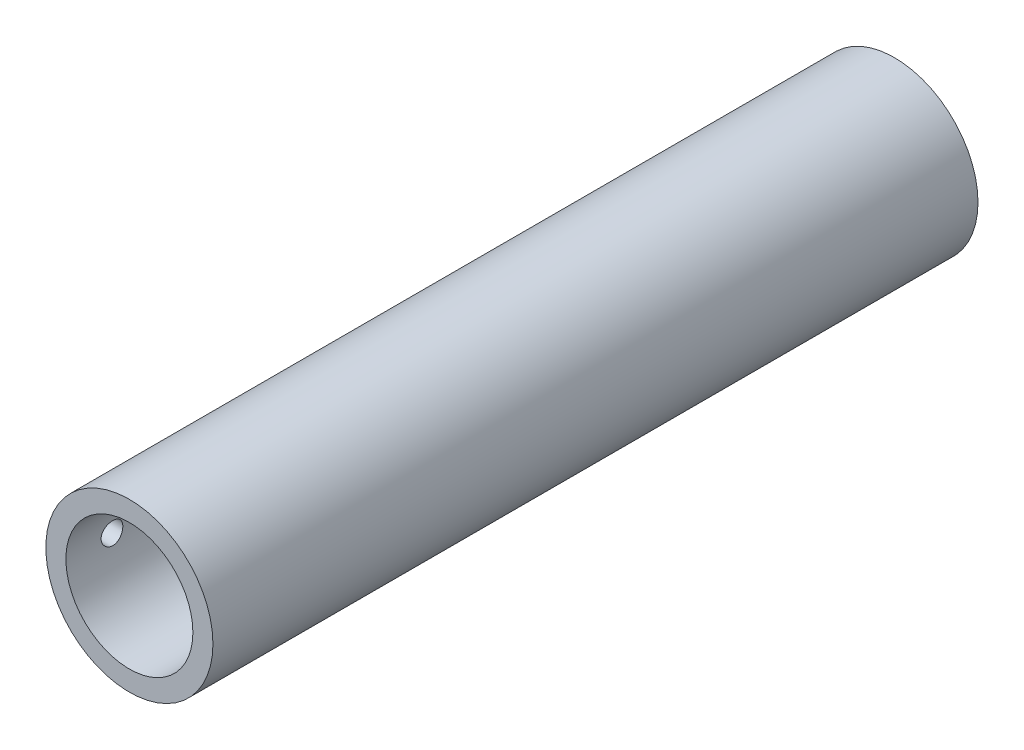
from build123d import *

# Parameters (mm, degrees)
SKETCH1_R           = 12.7
SKETCH1_R_2         = 9.652
BOSS_EXTRUDE1_DEPTH = 116.3
SKETCH2_R           = 1.65
CUT_EXTRUDE1_DEPTH  = 30


with BuildPart() as part:
    # Sketch1 → Boss-Extrude1 (new body)
    with BuildSketch(Plane.XY):
        Circle(SKETCH1_R)
        Circle(SKETCH1_R_2, mode=Mode.SUBTRACT)
    extrude(amount=BOSS_EXTRUDE1_DEPTH)

    # Sketch2 → Cut-Extrude1 (cut)
    with BuildSketch(Plane(origin=(0, 0, 0), x_dir=(0, 0, -1), z_dir=(1, 0, 0))):
        with Locations((-109.3, 0)):
            Circle(SKETCH2_R)
        with Locations((-29.8, 0)):
            Circle(SKETCH2_R)
        with Locations((-18, 0)):
            Circle(SKETCH2_R)
    extrude(amount=-CUT_EXTRUDE1_DEPTH, mode=Mode.SUBTRACT)


solid = part.part
